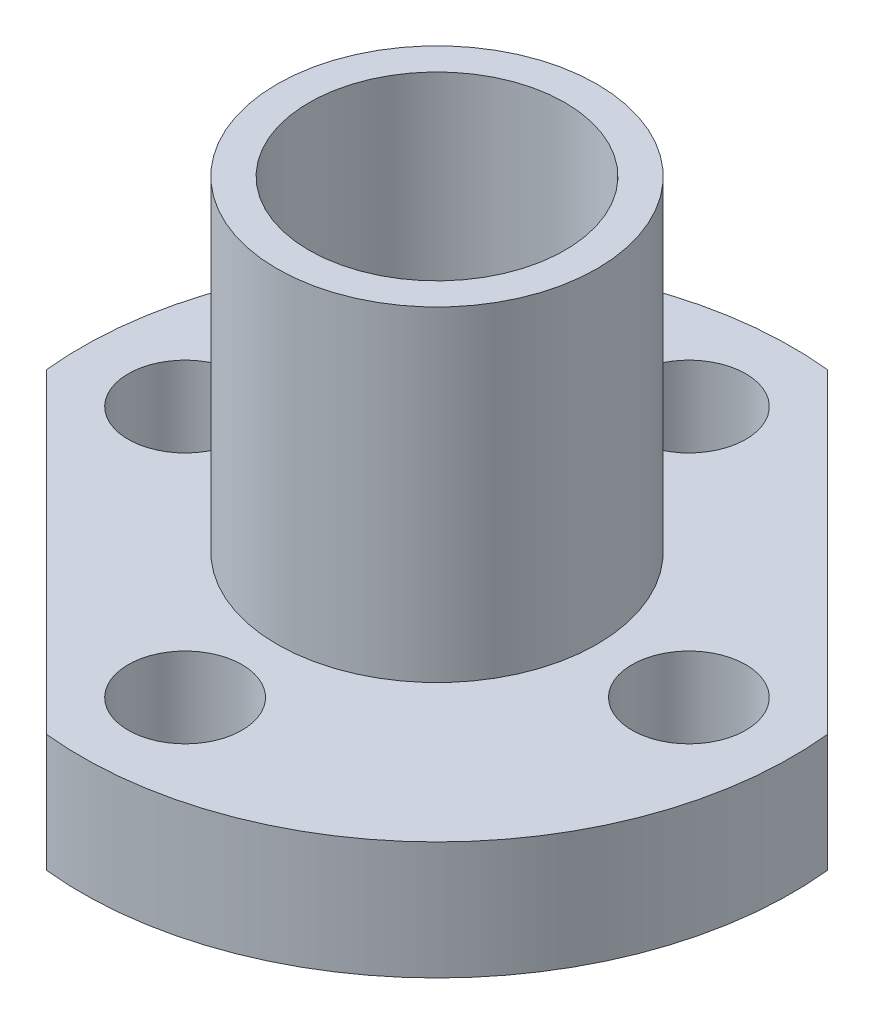
from build123d import *

# Parameters (mm, degrees)
SKETCH1_R           = 5
SKETCH1_R_2         = 4
BOSS_EXTRUDE1_DEPTH = 15.6
SKETCH2_R           = 11.1
SKETCH2_R_2         = 5
SKETCH2_R_3         = 1.778
BOSS_EXTRUDE2_DEPTH = 3.683
SKETCH3_OUTSIDE_W   = 31.212
SKETCH3_OUTSIDE_H   = 31.212
CUT_EXTRUDE1_DEPTH  = 14.849999944


with BuildPart() as part:
    # Sketch1 → Boss-Extrude1 (new body)
    with BuildSketch(Plane(origin=(0, 0, 0), x_dir=(1, 0, 0), z_dir=(0, 1, 0))):
        Circle(SKETCH1_R)
        Circle(SKETCH1_R_2, mode=Mode.SUBTRACT)
    extrude(amount=BOSS_EXTRUDE1_DEPTH)

    # Sketch2 → Boss-Extrude2 (add)
    with BuildSketch(Plane(origin=(0, 1.750000056, 0), x_dir=(-1, 0, 0), z_dir=(0, -1, 0))):
        Circle(SKETCH2_R)
        Circle(SKETCH2_R_2, mode=Mode.SUBTRACT)
        with Locations((0, 7.874)):
            Circle(SKETCH2_R_3, mode=Mode.SUBTRACT)
        with Locations((7.874, 0)):
            Circle(SKETCH2_R_3, mode=Mode.SUBTRACT)
        with Locations((0, -7.874)):
            Circle(SKETCH2_R_3, mode=Mode.SUBTRACT)
        with Locations((-7.874, 0)):
            Circle(SKETCH2_R_3, mode=Mode.SUBTRACT)
    extrude(amount=-BOSS_EXTRUDE2_DEPTH)

    # Sketch3 outside → Cut-Extrude1 (cut, through all)
    with BuildSketch(Plane.XZ.offset(-1.750000056)):
        Rectangle(SKETCH3_OUTSIDE_W, SKETCH3_OUTSIDE_H)
        Polygon((0.010892417, -12.202255907), (16.316615828, 4.103467504), (4.103467504, 16.316615828), (-15.606056949, -3.392908624), (-3.392908624, -15.606056949), align=None, mode=Mode.SUBTRACT)
    extrude(amount=-CUT_EXTRUDE1_DEPTH, mode=Mode.SUBTRACT)


solid = part.part
